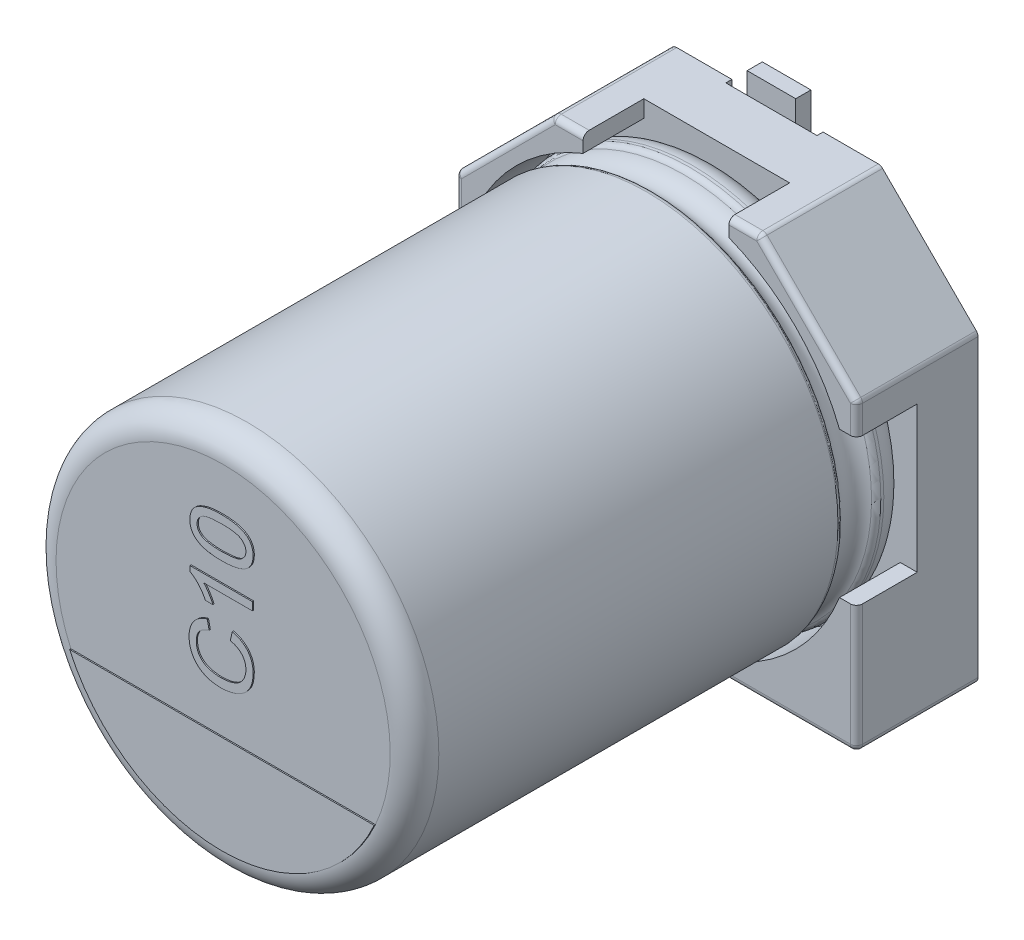
from build123d import *

# Parameters (mm, degrees)
BOSS_EXTRUDE1_DEPTH = 1
BOSS_EXTRUDE2_DEPTH = 1
SKETCH7_R           = 0.35
BOSS_EXTRUDE3_DEPTH = 0.15
SKETCH9_W           = 1.5
SKETCH9_H           = 2.3
CUT_EXTRUDE1_DEPTH  = 0.1
FILLET1_R           = 0.1
FILLET2_R           = 0.1
BOSS_EXTRUDE4_DEPTH = 0.02
BOSS_EXTRUDE5_DEPTH = 0.02
SKETCH19_W          = 0.8
SKETCH19_H          = 2.25
BOSS_EXTRUDE6_DEPTH = 0.25


with BuildPart() as part:
    # Sketch2 → Boss-Extrude1 (new body)
    with BuildSketch(Plane.XY):
        Polygon((-3.3, 1.7), (-1.7, 3.3), (1.7, 3.3), (3.3, 1.7), (3.3, -3.3), (-3.3, -3.3), align=None)
    extrude(amount=BOSS_EXTRUDE1_DEPTH)

    # Sketch4 → Boss-Extrude2 (add)
    with BuildSketch(Plane.XY.offset(1)):
        with BuildLine():
            Line((-3.3, 1.7), (-1.7, 3.3))
            Line((-1.7, 3.3), (-1.2, 3.3))
            Line((-1.2, 3.3), (-1.2, 3.020347662))
            ThreePointArc((-1.2, 3.020347662), (-2.298097039, 2.298097039), (-3.020347662, 1.2))
            Line((-3.020347662, 1.2), (-3.3, 1.2))
            Line((-3.3, 1.2), (-3.3, 1.7))
        make_face()
        with BuildLine():
            Line((1.7, 3.3), (3.3, 1.7))
            Line((3.3, 1.7), (3.3, 1.2))
            Line((3.3, 1.2), (3.020347662, 1.2))
            ThreePointArc((3.020347662, 1.2), (2.298097039, 2.298097039), (1.2, 3.020347662))
            Line((1.2, 3.020347662), (1.2, 3.3))
            Line((1.2, 3.3), (1.7, 3.3))
        make_face()
        with BuildLine():
            Line((3.3, -1.2), (3.3, -3.3))
            Line((3.3, -3.3), (1.2, -3.3))
            Line((1.2, -3.3), (1.2, -3.020347662))
            ThreePointArc((1.2, -3.020347662), (2.298097039, -2.298097039), (3.020347662, -1.2))
            Line((3.020347662, -1.2), (3.3, -1.2))
        make_face()
        with BuildLine():
            Line((-3.3, -1.2), (-3.3, -3.3))
            Line((-3.3, -3.3), (-1.2, -3.3))
            Line((-1.2, -3.3), (-1.2, -3.020347662))
            ThreePointArc((-1.2, -3.020347662), (-2.298097039, -2.298097039), (-3.020347662, -1.2))
            Line((-3.020347662, -1.2), (-3.3, -1.2))
        make_face()
    extrude(amount=BOSS_EXTRUDE2_DEPTH)

    # Sketch7 → Boss-Extrude3 (add)
    with BuildSketch(Plane(origin=(0, 0, 0), x_dir=(1, 0, 0), z_dir=(0, 0, -1))):
        with Locations((-2.232271432, 1.911844843)):
            Circle(SKETCH7_R)
        with Locations((2.232271432, 1.911844843)):
            Circle(SKETCH7_R)
        with Locations((-2.232271432, -1.911844843)):
            Circle(SKETCH7_R)
        with Locations((2.232271432, -1.911844843)):
            Circle(SKETCH7_R)
    extrude(amount=BOSS_EXTRUDE3_DEPTH)

    # Sketch9 → Cut-Extrude1 (cut)
    with BuildSketch(Plane(origin=(0, 0, 0), x_dir=(1, 0, 0), z_dir=(0, 0, -1))):
        with Locations((0, 2.15)):
            Rectangle(SKETCH9_W, SKETCH9_H)
        with Locations((0, -2.15)):
            Rectangle(SKETCH9_W, SKETCH9_H)
    extrude(amount=-CUT_EXTRUDE1_DEPTH, mode=Mode.SUBTRACT)

    # Fillet1
    fillet1_edges = [part.edges().sort_by_distance(p)[0] for p in [
        (3.3, -3.3, 1),
        (-3.3, -3.3, 1),
        (-3.3, 1.7, 1),
        (-1.7, 3.3, 1),
        (1.7, 3.3, 1),
        (3.3, 1.7, 1),
    ]]
    fillet(fillet1_edges, radius=FILLET1_R)

    # Sketch10 → Revolve1 (revolve)
    with BuildSketch(Plane(origin=(0, 0, 0), x_dir=(0, 0, -1), z_dir=(1, 0, 0))):
        with BuildLine():
            Line((-9.123626625, 0), (-1, 0))
            Line((-1, 0), (-1, 2.75))
            ThreePointArc((-1, 2.75), (-1.117157288, 3.032842712), (-1.4, 3.15))
            Line((-1.4, 3.15), (-1.449422929, 3.15))
            ThreePointArc((-1.449422929, 3.15), (-1.504479696, 3.133479053), (-1.541344666, 3.089375046))
            ThreePointArc((-1.541344666, 3.089375046), (-1.801990181, 2.917472047), (-2.062635697, 3.089375046))
            ThreePointArc((-2.062635697, 3.089375046), (-2.099500666, 3.133479053), (-2.154557434, 3.15))
            Line((-2.154557434, 3.15), (-8.723626625, 3.15))
            ThreePointArc((-8.723626625, 3.15), (-9.006469337, 3.032842712), (-9.123626625, 2.75))
            Line((-9.123626625, 2.75), (-9.123626625, 0))
        make_face()
    revolve(axis=Axis((0, 0, -18.9630778), (0, 0, 1)))

    # Fillet2
    fillet2_edges = [part.edges().sort_by_distance(p)[0] for p in [
        (2.2, -3.3, 2),
        (3.270710678, -3.270710678, 2),
        (3.3, 1.429289322, 2),
        (3.292387953, 1.696846987, 2),
        (1.429289322, 3.3, 2),
        (1.696846987, 3.292387953, 2),
        (-1.429289322, 3.3, 2),
        (-1.696846987, 3.292387953, 2),
        (-2.5, 2.5, 2),
        (-3.292387953, 1.696846987, 2),
        (-3.3, -2.2, 2),
        (-3.270710678, -3.270710678, 2),
        (3.3, -2.2, 2),
        (2.5, 2.5, 2),
        (-3.3, 1.429289322, 2),
        (-2.2, -3.3, 2),
    ]]
    fillet(fillet2_edges, radius=FILLET2_R)

    # Sketch13 → Boss-Extrude4 (add)
    with BuildSketch(Plane.XY.offset(9.123626625)):
        with BuildLine():
            Line((-2.506238836, -1.131930607), (2.506238836, -1.131930607))
            ThreePointArc((2.506238836, -1.131930607), (0, -2.75), (-2.506238836, -1.131930607))
        make_face()
    extrude(amount=BOSS_EXTRUDE4_DEPTH)

    # Sketch15 → Boss-Extrude5 (add)
    with BuildSketch(Plane.XY.offset(9.123626625)):
        with BuildLine():
            Line((0.137389622, 0.316593633), (0.171139963, 0.461473149))
            add(Edge.make_bspline(
                [(0.171139963, 0.461473149), (0.184719205, 0.457843617), (0.211281888, 0.450743802), (0.249294555, 0.436704736), (0.284973396, 0.420954535), (0.318198658, 0.403080099), (0.348825876, 0.383025378), (0.37700883, 0.360877976), (0.402792333, 0.336641169), (0.425858287, 0.31012897), (0.446489175, 0.282031663), (0.464171898, 0.252152583), (0.479591278, 0.221021834), (0.491950748, 0.188130242), (0.501325327, 0.153719305), (0.508136304, 0.117874786), (0.512336792, 0.080509598), (0.512889354, 0.055039538), (0.513170865, 0.042063415)],
                knots=[0, 0, 0, 0, 1.145367768, 2.240481511, 3.299486216, 4.322926322, 5.312543435, 6.280301985, 7.2416403, 8.192823262, 9.141388579, 10.079393599, 11.019812878, 11.970222822, 12.938950422, 13.923894909, 14.942295558, 16, 16, 16, 16], degree=3))
            add(Edge.make_bspline(
                [(0.513170865, 0.042063415), (0.512974968, 0.028750287), (0.512591712, 0.002704216), (0.509548347, -0.035461334), (0.50408886, -0.071710574), (0.497105361, -0.106172698), (0.487517876, -0.138603304), (0.476080502, -0.169237106), (0.462232577, -0.197809744), (0.446522059, -0.224623591), (0.428664346, -0.249552903), (0.409152567, -0.273167676), (0.387446592, -0.294893809), (0.364059715, -0.315274756), (0.338683214, -0.333866555), (0.311661899, -0.351353217), (0.282519639, -0.366881226), (0.251796737, -0.381026037), (0.219790643, -0.393441241), (0.187133568, -0.404424353), (0.153760439, -0.413403647), (0.119952084, -0.421134241), (0.085424029, -0.426750142), (0.050435341, -0.431208994), (0.014771509, -0.433660561), (-0.009201459, -0.433983161), (-0.021278143, -0.434145675)],
                knots=[0, 0, 0, 0, 1.180680974, 2.309907975, 3.39230657, 4.430402719, 5.425739985, 6.38846843, 7.327253855, 8.238163682, 9.141319901, 10.044148192, 10.951882972, 11.861898394, 12.79276478, 13.739539846, 14.714057202, 15.718574761, 16.737652364, 17.7573291, 18.772768038, 19.801551793, 20.831755737, 21.873891013, 22.928945814, 24, 24, 24, 24], degree=3))
            add(Edge.make_bspline(
                [(-0.021278143, -0.434145675), (-0.034315397, -0.4339132), (-0.060073717, -0.433453889), (-0.098081116, -0.430862244), (-0.134761949, -0.426098769), (-0.17014477, -0.419495443), (-0.204305873, -0.411082573), (-0.23725329, -0.400840529), (-0.268852986, -0.388622281), (-0.299113504, -0.374745627), (-0.327665253, -0.358785546), (-0.354762577, -0.3416054), (-0.379878011, -0.322520006), (-0.403474105, -0.302187934), (-0.425149261, -0.280085417), (-0.444954877, -0.256284136), (-0.463070995, -0.230988325), (-0.479329594, -0.204201975), (-0.493595656, -0.176275134), (-0.506302564, -0.147622628), (-0.516717602, -0.118130488), (-0.525377287, -0.088032537), (-0.532271201, -0.057263976), (-0.536881183, -0.025752912), (-0.539885404, 0.006471539), (-0.540292549, 0.02819978), (-0.540498339, 0.039182288)],
                knots=[0, 0, 0, 0, 1.185610122, 2.34246615, 3.46204209, 4.547238403, 5.613845268, 6.659506797, 7.682407252, 8.692734231, 9.683951048, 10.654680354, 11.607833779, 12.549673105, 13.484816388, 14.419272854, 15.362680812, 16.31159957, 17.265732262, 18.21261905, 19.159670199, 20.10733745, 21.059306249, 22.024427552, 23.00144979, 24, 24, 24, 24], degree=3))
            add(Edge.make_bspline(
                [(-0.540498339, 0.039182288), (-0.54027585, 0.051472155), (-0.539838527, 0.075629106), (-0.53596558, 0.111030265), (-0.53016218, 0.145076857), (-0.521400985, 0.17750367), (-0.510653256, 0.208616176), (-0.496791219, 0.237924274), (-0.481084534, 0.266024209), (-0.462639265, 0.292395393), (-0.442059798, 0.317116672), (-0.419396701, 0.339965227), (-0.394799964, 0.360899322), (-0.368077184, 0.379659831), (-0.339408707, 0.396504218), (-0.308850674, 0.411613497), (-0.276208278, 0.424627676), (-0.253468798, 0.431587541), (-0.241890133, 0.435131419)],
                knots=[0, 0, 0, 0, 1.098215313, 2.158650937, 3.179873416, 4.182349117, 5.157851008, 6.118027029, 7.076341197, 8.032298369, 8.990121974, 9.948357669, 10.905435138, 11.873450097, 12.863034414, 13.874936208, 14.917943528, 16, 16, 16, 16], degree=3))
            Line((-0.241890133, 0.435131419), (-0.210815123, 0.290251903))
            add(Edge.make_bspline(
                [(-0.210815123, 0.290251903), (-0.21970095, 0.287406696), (-0.237093262, 0.281837744), (-0.261880399, 0.271949526), (-0.284890959, 0.26127058), (-0.305968529, 0.249546525), (-0.325118157, 0.236751953), (-0.342572578, 0.223181488), (-0.358006003, 0.208509995), (-0.371774287, 0.193035906), (-0.383503548, 0.176359634), (-0.393897604, 0.158872143), (-0.402497099, 0.140204709), (-0.409770496, 0.120625878), (-0.415306335, 0.099952647), (-0.419201016, 0.078269202), (-0.421455067, 0.05555649), (-0.421789822, 0.040079052), (-0.421960554, 0.032185266)],
                knots=[0, 0, 0, 0, 1.235697765, 2.418642872, 3.532555292, 4.594392283, 5.610119701, 6.580908344, 7.519430642, 8.427315627, 9.319973334, 10.216139639, 11.118687699, 12.038725643, 12.980015607, 13.949697744, 14.954307006, 16, 16, 16, 16], degree=3))
            add(Edge.make_bspline(
                [(-0.421960554, 0.032185266), (-0.42182894, 0.023122531), (-0.421570094, 0.005298806), (-0.418741414, -0.020887312), (-0.414566199, -0.046031584), (-0.408336958, -0.06996279), (-0.400471327, -0.092727501), (-0.391074044, -0.1144289), (-0.379637086, -0.134923416), (-0.366527285, -0.154190234), (-0.351810113, -0.172119905), (-0.335998775, -0.188775555), (-0.319056253, -0.204115277), (-0.300881808, -0.217955028), (-0.281409051, -0.230297385), (-0.260823414, -0.241466755), (-0.238987177, -0.251110914), (-0.208358467, -0.262011565), (-0.168833348, -0.2727293), (-0.120495718, -0.282252213), (-0.071437696, -0.288256875), (-0.038444502, -0.28892902), (-0.021895528, -0.289266159)],
                knots=[0, 0, 0, 0, 0.935100075, 1.839065892, 2.715632844, 3.564034634, 4.388093667, 5.199800233, 6.00171917, 6.806945003, 7.602082793, 8.393428172, 9.17553264, 9.958694158, 10.748327009, 11.553054559, 12.374096334, 13.209545573, 14.906836637, 16.595465087, 18.292327764, 20, 20, 20, 20], degree=3))
            add(Edge.make_bspline(
                [(-0.021895528, -0.289266159), (-0.001088295, -0.28888169), (0.039347759, -0.288134525), (0.097860474, -0.280941105), (0.152411861, -0.269796756), (0.194923463, -0.256480088), (0.226325575, -0.243084208), (0.248317261, -0.232252213), (0.268667217, -0.219887416), (0.287491124, -0.206297945), (0.304734045, -0.191308606), (0.320487583, -0.175128268), (0.334903322, -0.157753307), (0.347306436, -0.138977849), (0.35831932, -0.119524584), (0.368112186, -0.099638997), (0.376394559, -0.079308568), (0.382828475, -0.058451271), (0.388388272, -0.03736), (0.392020193, -0.015802455), (0.394069935, 0.006215216), (0.39444386, 0.020999538), (0.39463308, 0.02848096)],
                knots=[0, 0, 0, 0, 2.106854985, 4.094388766, 5.961441423, 7.741458329, 8.594569961, 9.418076185, 10.222480919, 11.003619353, 11.767127393, 12.533696482, 13.289066307, 14.050325982, 14.809648647, 15.552384038, 16.294338903, 17.030544626, 17.761979889, 18.502240791, 19.242077596, 20, 20, 20, 20], degree=3))
            add(Edge.make_bspline(
                [(0.39463308, 0.02848096), (0.39444584, 0.037409013), (0.394075974, 0.055045074), (0.390838523, 0.080901779), (0.386067714, 0.105827286), (0.378705874, 0.129519626), (0.369692165, 0.152297488), (0.358576684, 0.173974247), (0.345208005, 0.194481731), (0.330029126, 0.214061155), (0.312758155, 0.232351457), (0.293534236, 0.249113535), (0.27226973, 0.264151013), (0.249305901, 0.278094539), (0.223956735, 0.289809664), (0.196977778, 0.300660635), (0.167925608, 0.309702449), (0.147714502, 0.314263574), (0.137389622, 0.316593633)],
                knots=[0, 0, 0, 0, 1.013374089, 2.001772144, 2.95501459, 3.891367103, 4.814208647, 5.733921849, 6.652182523, 7.590185968, 8.54346024, 9.504121027, 10.481158517, 11.497760682, 12.549996529, 13.647863555, 14.798406869, 16, 16, 16, 16], degree=3))
        make_face()
        with BuildLine():
            Line((0.5, 1.054162076), (0.5, 0.922453425))
            Line((0.5, 0.922453425), (-0.300541641, 0.922453425))
            add(Edge.make_bspline(
                [(-0.300541641, 0.922453425), (-0.293231008, 0.914867413), (-0.278036657, 0.899100718), (-0.256498368, 0.872525657), (-0.234933587, 0.842661098), (-0.213972558, 0.810225794), (-0.193975357, 0.777264423), (-0.17626551, 0.745237618), (-0.16122985, 0.714930294), (-0.153017422, 0.694960397), (-0.149076693, 0.685377855)],
                knots=[0, 0, 0, 0, 0.893410138, 1.856855062, 2.898678959, 4.017251132, 5.132047586, 6.168690112, 7.121247105, 8, 8, 8, 8], degree=3))
            Line((-0.149076693, 0.685377855), (-0.270495605, 0.685377855))
            add(Edge.make_bspline(
                [(-0.270495605, 0.685377855), (-0.278975965, 0.701832813), (-0.295690253, 0.734264562), (-0.324502419, 0.780173657), (-0.356038954, 0.822817654), (-0.389687464, 0.861943114), (-0.424153619, 0.896834541), (-0.458713989, 0.92646811), (-0.492500166, 0.951068711), (-0.516061848, 0.963453197), (-0.527327474, 0.969374632)],
                knots=[0, 0, 0, 0, 1.141359047, 2.249551097, 3.338622382, 4.409719606, 5.42990334, 6.36011437, 7.215916014, 8, 8, 8, 8], degree=3))
            Line((-0.527327474, 0.969374632), (-0.527327474, 1.054162076))
            Line((-0.527327474, 1.054162076), (0.5, 1.054162076))
        make_face()
        with BuildLine():
            add(Edge.make_bspline(
                [(-0.006666715, 1.383433702), (-0.021348161, 1.383566435), (-0.05010293, 1.383826401), (-0.092176441, 1.385437954), (-0.132131476, 1.388254232), (-0.169935305, 1.392449442), (-0.205733207, 1.397454989), (-0.239429592, 1.403867562), (-0.271062963, 1.411184505), (-0.300511033, 1.419860467), (-0.328087047, 1.429543425), (-0.353841772, 1.440380117), (-0.37776862, 1.452612868), (-0.400036721, 1.465712401), (-0.420488167, 1.479932501), (-0.439160067, 1.495255191), (-0.456112672, 1.511706922), (-0.471148561, 1.529458766), (-0.484427043, 1.548340503), (-0.495950274, 1.568301249), (-0.505765593, 1.58948262), (-0.513455163, 1.611944973), (-0.519644259, 1.635469504), (-0.524219468, 1.660149349), (-0.526911348, 1.686028494), (-0.527187198, 1.703712594), (-0.527327474, 1.712705329)],
                knots=[0, 0, 0, 0, 1.514579231, 2.966422906, 4.342888004, 5.645649548, 6.889653673, 8.070797339, 9.183112822, 10.237837631, 11.23608981, 12.196917133, 13.117904763, 14.006315217, 14.860292005, 15.684850496, 16.495566347, 17.293863258, 18.081168691, 18.873799386, 19.668575398, 20.485475899, 21.319695627, 22.176102692, 23.072510053, 24, 24, 24, 24], degree=3))
            add(Edge.make_bspline(
                [(-0.527327474, 1.712705329), (-0.526946, 1.725900851), (-0.52619658, 1.751823984), (-0.519894074, 1.789619905), (-0.509601404, 1.825365362), (-0.495164597, 1.858771713), (-0.477005039, 1.889551399), (-0.454609486, 1.916814349), (-0.428796734, 1.940721356), (-0.398935516, 1.960698215), (-0.365916888, 1.978175601), (-0.32956484, 1.993697591), (-0.289928116, 2.007730365), (-0.254447235, 2.017688005), (-0.223818989, 2.024790857), (-0.198557662, 2.029492369), (-0.171300552, 2.033395569), (-0.142113597, 2.036385948), (-0.111029533, 2.038839483), (-0.078029007, 2.040734235), (-0.043029539, 2.041696016), (-0.019014885, 2.041881553), (-0.006666715, 2.041976955)],
                knots=[0, 0, 0, 0, 1.134369906, 2.228515181, 3.285355733, 4.326599491, 5.350616376, 6.348601676, 7.350764122, 8.365406289, 9.429174435, 10.560286681, 11.762070813, 13.043401781, 13.727542782, 14.465843617, 15.252693982, 16.095180924, 16.988916914, 17.934437918, 18.937902156, 20, 20, 20, 20], degree=3))
            add(Edge.make_bspline(
                [(-0.006666715, 2.041976955), (0.007945774, 2.041841762), (0.036494148, 2.041577635), (0.078230238, 2.04000893), (0.117884052, 2.037024283), (0.155547122, 2.033354152), (0.191116489, 2.027792706), (0.224685881, 2.021840905), (0.256141409, 2.014381948), (0.285591451, 2.005734402), (0.313215971, 1.996076626), (0.339056183, 1.985437014), (0.363042027, 1.973440215), (0.385265653, 1.96031548), (0.405728202, 1.94602942), (0.424578214, 1.930841433), (0.441550249, 1.914321801), (0.456560003, 1.896506184), (0.470080131, 1.877750835), (0.481656405, 1.857683963), (0.49124711, 1.836393055), (0.499446696, 1.814020456), (0.50545487, 1.790339138), (0.510054034, 1.765535857), (0.512762354, 1.739519222), (0.513032816, 1.72176661), (0.513170865, 1.712705329)],
                knots=[0, 0, 0, 0, 1.509004079, 2.9481365, 4.311841541, 5.615149582, 6.854413858, 8.028470806, 9.134999426, 10.19077436, 11.196702255, 12.155743144, 13.07445799, 13.963752978, 14.818580019, 15.649443378, 16.460966408, 17.260058134, 18.052243746, 18.845663614, 19.647670084, 20.461076897, 21.302979722, 22.167206202, 23.06450606, 24, 24, 24, 24], degree=3))
            add(Edge.make_bspline(
                [(0.513170865, 1.712705329), (0.512831976, 1.700824938), (0.512171236, 1.677661445), (0.507681916, 1.643832872), (0.499780502, 1.612082952), (0.489183591, 1.582143893), (0.475009612, 1.554352217), (0.457764199, 1.528575231), (0.437848585, 1.504294964), (0.422135623, 1.490317766), (0.414183582, 1.483244164)],
                knots=[0, 0, 0, 0, 1.10322584, 2.150986741, 3.161425019, 4.136713905, 5.093944212, 6.049774532, 7.013026876, 8, 8, 8, 8], degree=3))
            add(Edge.make_bspline(
                [(0.414183582, 1.483244164), (0.402438803, 1.475102286), (0.378220566, 1.458313384), (0.336926225, 1.43866343), (0.291466953, 1.421135323), (0.240950845, 1.407378973), (0.185779952, 1.396604321), (0.125846017, 1.388822333), (0.061174934, 1.384418493), (0.016457663, 1.383769376), (-0.006666715, 1.383433702)],
                knots=[0, 0, 0, 0, 0.779365345, 1.607084704, 2.489375761, 3.438383567, 4.461919411, 5.557722155, 6.737039282, 8, 8, 8, 8], degree=3))
        make_face()
        with BuildLine():
            add(Edge.make_bspline(
                [(-0.007078304, 1.515142353), (0.012680939, 1.515273129), (0.050504503, 1.515523464), (0.104541989, 1.518138853), (0.153291178, 1.522641137), (0.196684572, 1.528593451), (0.234780871, 1.536452916), (0.267482993, 1.546321403), (0.295183438, 1.557445536), (0.31753888, 1.571211439), (0.335761826, 1.586283582), (0.351434149, 1.601844541), (0.364755265, 1.618260409), (0.375862359, 1.635424076), (0.384271921, 1.653601848), (0.39036719, 1.672594954), (0.393874924, 1.692407528), (0.394378919, 1.705900791), (0.39463308, 1.712705329)],
                knots=[0, 0, 0, 0, 1.89448813, 3.626469325, 5.185477471, 6.587276848, 7.82441448, 8.910550357, 9.859733512, 10.6775885, 11.416198291, 12.123144072, 12.791880183, 13.439617036, 14.078171869, 14.70637855, 15.347637704, 16, 16, 16, 16], degree=3))
            add(Edge.make_bspline(
                [(0.39463308, 1.712705329), (0.394373432, 1.719508217), (0.393858557, 1.732998211), (0.390427197, 1.752855758), (0.384021797, 1.771777976), (0.375628132, 1.789917263), (0.364803962, 1.807286144), (0.351188379, 1.823477079), (0.335563636, 1.839212453), (0.31713255, 1.854123894), (0.294785049, 1.867980664), (0.267067011, 1.879083781), (0.234370941, 1.888961166), (0.196338005, 1.896794927), (0.153019756, 1.902789575), (0.104403712, 1.907259025), (0.050436387, 1.909893637), (0.012681078, 1.910139586), (-0.007078304, 1.910268304)],
                knots=[0, 0, 0, 0, 0.652578524, 1.294050225, 1.924494109, 2.563260593, 3.207694917, 3.880813851, 4.587993952, 5.331957758, 6.150083828, 7.099581593, 8.186077474, 9.42362516, 10.819375359, 12.378900244, 14.104883934, 16, 16, 16, 16], degree=3))
            add(Edge.make_bspline(
                [(-0.007078304, 1.910268304), (-0.02642651, 1.910143578), (-0.063496939, 1.909904609), (-0.116493392, 1.907203811), (-0.164424345, 1.902971418), (-0.207333987, 1.897182177), (-0.245175733, 1.889488277), (-0.278030144, 1.880156626), (-0.305827152, 1.869036569), (-0.328845978, 1.85581486), (-0.34772766, 1.841096453), (-0.364071399, 1.825721681), (-0.377971216, 1.809306174), (-0.389121855, 1.791559098), (-0.398117775, 1.773052475), (-0.404308997, 1.75336107), (-0.40811269, 1.732678434), (-0.408561444, 1.718484209), (-0.408789689, 1.711264765)],
                knots=[0, 0, 0, 0, 1.850066095, 3.544656626, 5.0727657, 6.45041401, 7.682899467, 8.762389858, 9.712573485, 10.538438529, 11.291566246, 11.996865408, 12.681389046, 13.341983376, 13.996294293, 14.643563182, 15.31009126, 16, 16, 16, 16], degree=3))
            add(Edge.make_bspline(
                [(-0.408789689, 1.711264765), (-0.408612967, 1.704459779), (-0.408264494, 1.691041217), (-0.404876647, 1.671409791), (-0.399346117, 1.652720616), (-0.39136817, 1.635098068), (-0.381470743, 1.618367712), (-0.369432495, 1.602509246), (-0.354882974, 1.587902895), (-0.343982304, 1.579112371), (-0.338407878, 1.57461704)],
                knots=[0, 0, 0, 0, 1.021462953, 2.014194051, 2.982449609, 3.941891643, 4.91211921, 5.897280499, 6.924703483, 8, 8, 8, 8], degree=3))
            add(Edge.make_bspline(
                [(-0.338407878, 1.57461704), (-0.330223621, 1.569721616), (-0.312940192, 1.559383511), (-0.282899948, 1.547820081), (-0.248509791, 1.537565623), (-0.209345493, 1.529236978), (-0.165460838, 1.523074155), (-0.116925816, 1.518301083), (-0.063560809, 1.515797668), (-0.026425263, 1.515366818), (-0.007078304, 1.515142353)],
                knots=[0, 0, 0, 0, 0.671109831, 1.417242661, 2.260125669, 3.199948126, 4.23589883, 5.382398214, 6.636276086, 8, 8, 8, 8], degree=3))
        make_face(mode=Mode.SUBTRACT)
    extrude(amount=BOSS_EXTRUDE5_DEPTH)

    # Sketch19 → Boss-Extrude6 (add)
    with BuildSketch(Plane(origin=(0, 0, 0.1), x_dir=(1, 0, 0), z_dir=(0, 0, -1))):
        with Locations((0, 2.525)):
            Rectangle(SKETCH19_W, SKETCH19_H)
        with Locations((0, -2.525)):
            Rectangle(SKETCH19_W, SKETCH19_H)
    extrude(amount=BOSS_EXTRUDE6_DEPTH)


solid = part.part
